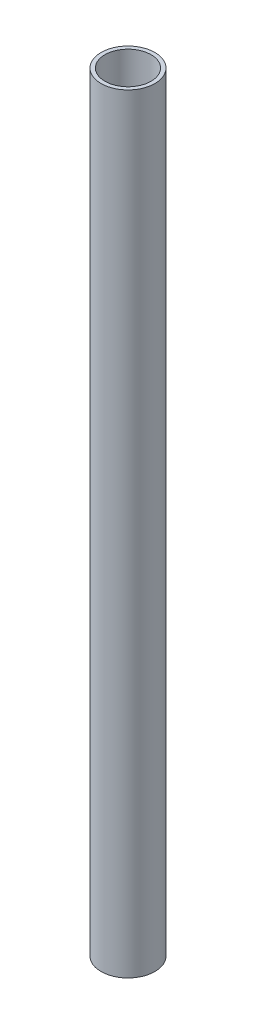
from build123d import *

# Parameters (mm, degrees)
SKETCH_1_R      = 7
SKETCH_1_R_2    = 6
EXTRUDE_1_DEPTH = 200


with BuildPart() as part:
    # Эскиз1 → Бобышка-Вытянуть1 (new body)
    with BuildSketch(Plane(origin=(0, 0, 0), x_dir=(1, 0, 0), z_dir=(0, 1, 0))):
        Circle(SKETCH_1_R)
        Circle(SKETCH_1_R_2, mode=Mode.SUBTRACT)
    extrude(amount=EXTRUDE_1_DEPTH)


solid = part.part
